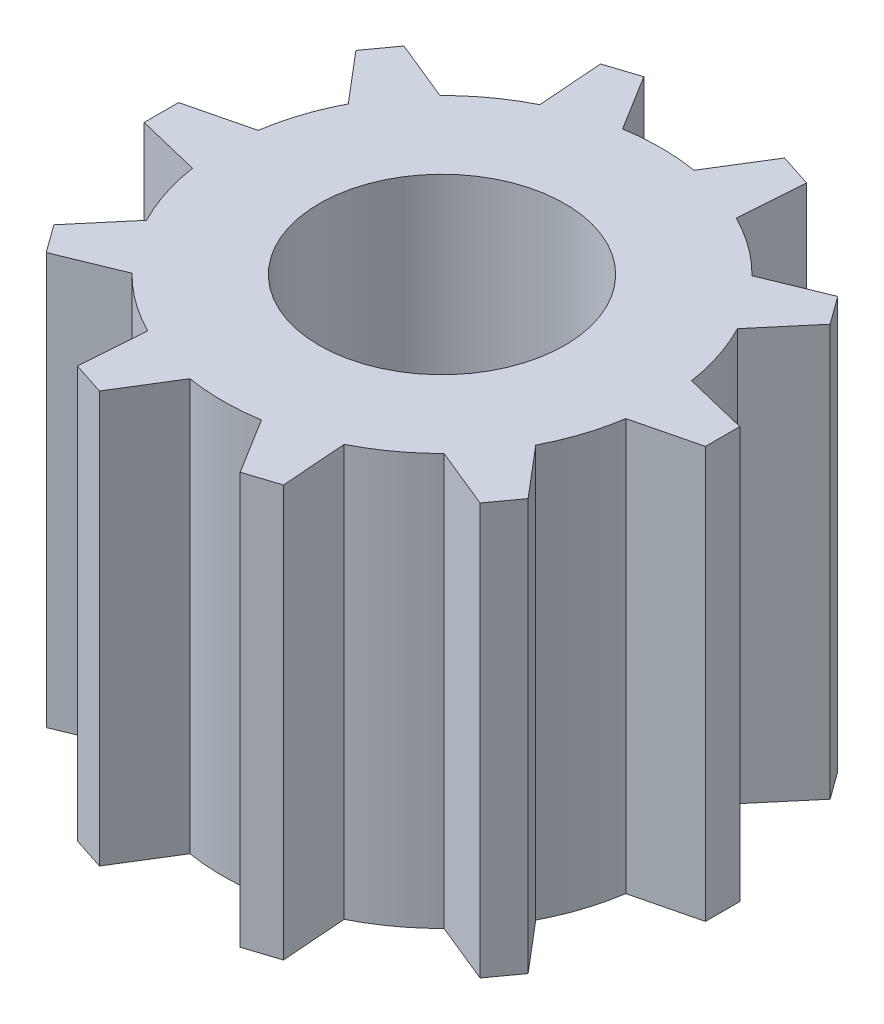
from build123d import *

# Parameters (mm, degrees)
SKETCH1_R           = 3.57
BOSS_EXTRUDE1_DEPTH = 6.7
CIRPATTERN1_COUNT   = 10
SKETCH2_R           = 2
CUT_EXTRUDE1_DEPTH  = 6.7


with BuildPart() as part:
    # Sketch1 → Boss-Extrude1 (new body)
    with BuildSketch(Plane(origin=(0, 0, 0), x_dir=(1, 0, 0), z_dir=(0, 1, 0))):
        Circle(SKETCH1_R)
        with BuildLine():
            Line((4.57, 0), (4.57, -0.28))
            Line((4.57, -0.28), (3.265257749, -0.600409723))
            ThreePointArc((3.265257749, -0.600409723), (3.319999856, -0.000976281), (3.265610298, 0.598489252))
            Line((3.265610298, 0.598489252), (4.57, 0.28))
            Line((4.57, 0.28), (4.57, 0))
        make_face()
    boss_extrude1 = extrude(amount=BOSS_EXTRUDE1_DEPTH)

    # CirPattern1: Boss-Extrude1 ×10 about axis
    cirpattern1_axis = Axis((0, 0, 0), (0, 1, 0))
    for i in range(1, CIRPATTERN1_COUNT):
        add(boss_extrude1.rotate(cirpattern1_axis, i * 360 / CIRPATTERN1_COUNT))

    # Sketch2 → Cut-Extrude1 (cut)
    with BuildSketch(Plane(origin=(0, 6.7, 0), x_dir=(1, 0, 0), z_dir=(0, 1, 0))):
        Circle(SKETCH2_R)
    extrude(amount=-CUT_EXTRUDE1_DEPTH, mode=Mode.SUBTRACT)


solid = part.part
